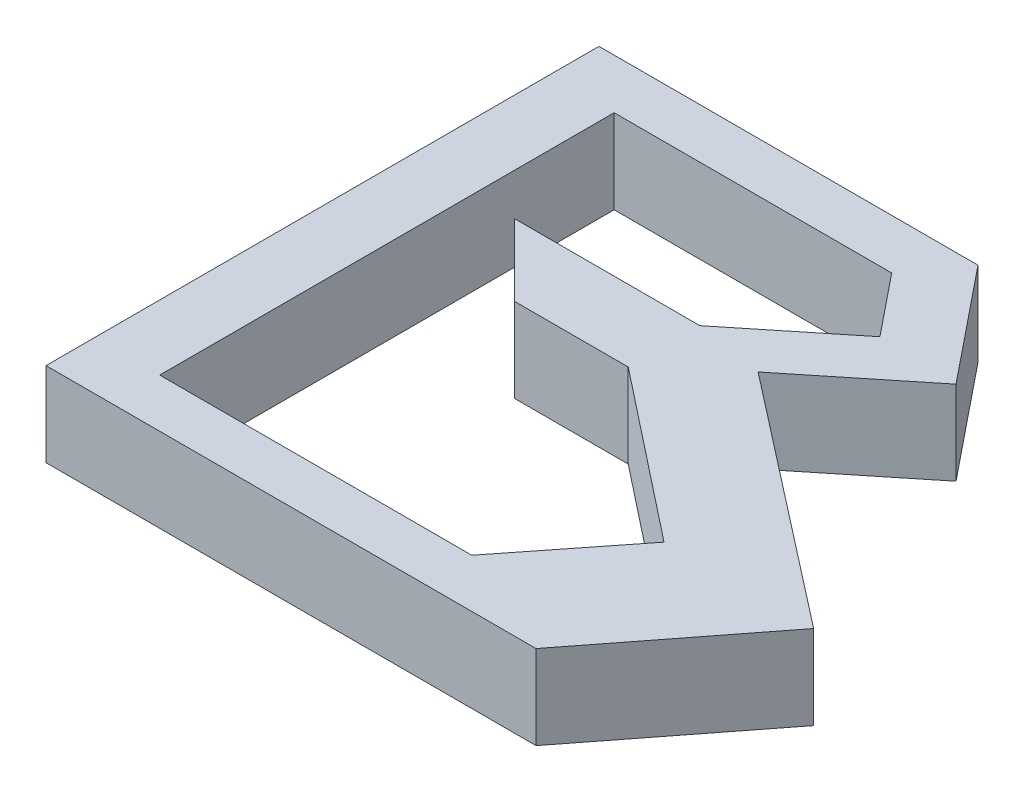
from build123d import *

# Parameters (mm, degrees)
BOSS_EXTRUDE1_DEPTH = 10


with BuildPart() as part:
    # Sketch1 → Boss-Extrude1 (new body)
    with BuildSketch(Plane(origin=(0, 0, 0), x_dir=(1, 0, 0), z_dir=(0, 1, 0))):
        Polygon((-31.591389498, 41.649056358), (-31.591389498, -24.112611576), (26.691500514, -24.112611576), (41.13327857, -5.544611218), (11.406624151, 17.576119997), (24.431058906, 28.088776811), (13.485895614, 41.649056358), align=None)
        Polygon((-23.854722682, 35.717611799), (9.155055732, 35.717611799), (15.022851217, 28.447830164), (3.172826817, 18.883097253), (-18.883097253, 18.883097253), (-10.365163505, 10.365163505), (3.172826817, 10.365163505), (23.338944894, -5.544611218), (13.255885856, -18.325191879), (-23.854722682, -18.325191879), align=None, mode=Mode.SUBTRACT)
    extrude(amount=BOSS_EXTRUDE1_DEPTH)


solid = part.part
